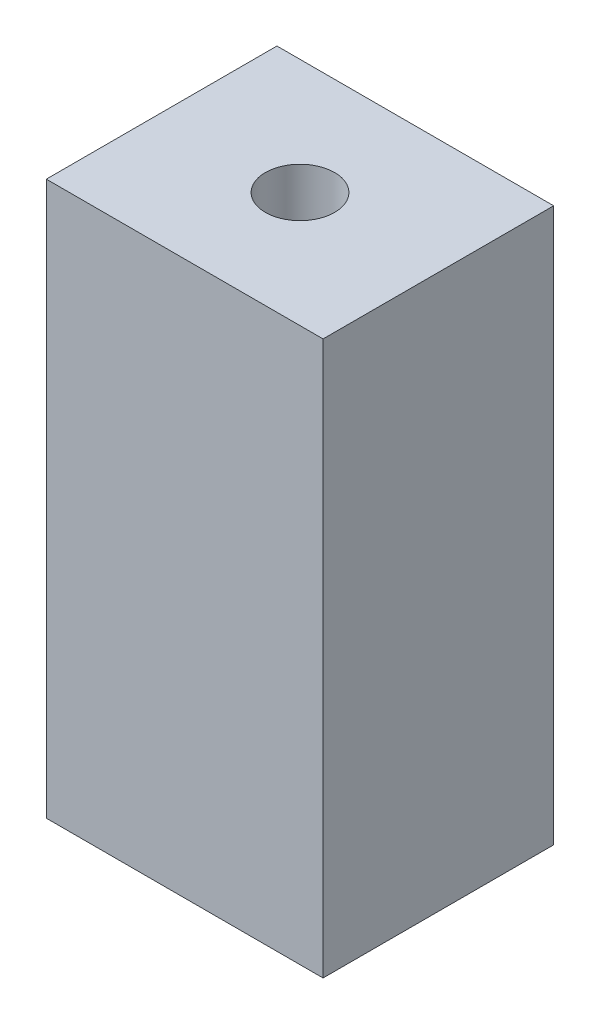
from build123d import *

# Parameters (mm, degrees)
SKETCH1_W                          = 12
SKETCH1_H                          = 10
SKETCH1_R                          = 1.5
BOSS_EXTRUDE1_DEPTH                = 24
SKETCH2_R                          = 1.754
SKETCH2_R_2                        = 1.5
BOSS_EXTRUDE2_DEPTH                = 0.5
TAP_DRILL_FOR_M1_6X0_35_TAP1_D     = 1.25
TAP_DRILL_FOR_M1_6X0_35_TAP1_DEPTH = 0.624460113
TAP_DRILL_FOR_M1_6X0_35_TAP1_TIP   = 0.375537887


with BuildPart() as part:
    # Sketch1 → Boss-Extrude1 (new body)
    with BuildSketch(Plane(origin=(0, 0, 0), x_dir=(1, 0, 0), z_dir=(0, 1, 0))):
        Rectangle(SKETCH1_W, SKETCH1_H)
        Circle(SKETCH1_R, mode=Mode.SUBTRACT)
    extrude(amount=BOSS_EXTRUDE1_DEPTH)

    # Sketch2 → Boss-Extrude2 (add)
    with BuildSketch(Plane.XZ):
        Circle(SKETCH2_R)
        Circle(SKETCH2_R_2, mode=Mode.SUBTRACT)
    extrude(amount=BOSS_EXTRUDE2_DEPTH)

    # Tap Drill for M1.6x0.35 Tap1
    with Locations(Plane(origin=(0, 0, 0), x_dir=(-1, 0, 0), z_dir=(0, -1, 0))):
        with Locations((-4.5, 0), (4.5, 0)):
            Hole(TAP_DRILL_FOR_M1_6X0_35_TAP1_D / 2, depth=TAP_DRILL_FOR_M1_6X0_35_TAP1_DEPTH)
            with Locations((0, 0, -(TAP_DRILL_FOR_M1_6X0_35_TAP1_DEPTH + TAP_DRILL_FOR_M1_6X0_35_TAP1_TIP / 2))):  # 118° drill point
                Cone(0, TAP_DRILL_FOR_M1_6X0_35_TAP1_D / 2, TAP_DRILL_FOR_M1_6X0_35_TAP1_TIP, mode=Mode.SUBTRACT)


solid = part.part
